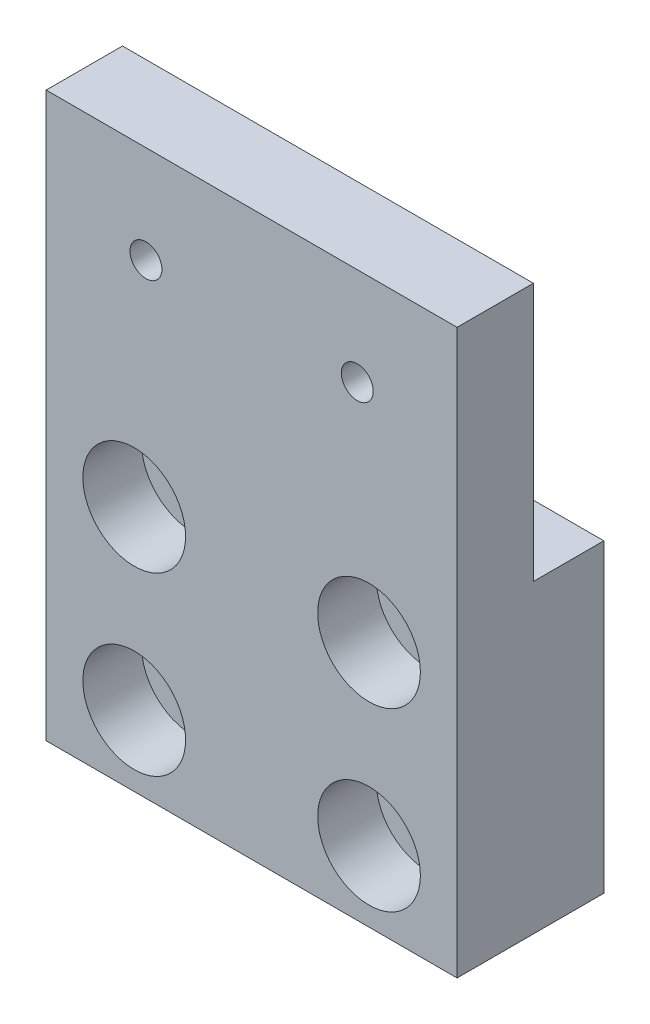
from build123d import *

# Parameters (mm, degrees)
SKETCH1_W                                        = 44.45
SKETCH1_H                                        = 60.96
BOSS_EXTRUDE1_DEPTH                              = 7.9375
CBORE_FOR_1_4_SOCKET_HEAD_CAP_SCREW1_D           = 6.7564
CBORE_FOR_1_4_SOCKET_HEAD_CAP_SCREW1_CBORE_D     = 11.1125
CBORE_FOR_1_4_SOCKET_HEAD_CAP_SCREW1_CBORE_DEPTH = 6.35
SKETCH4_W                                        = 7.62
SKETCH4_H                                        = 27.94
CUT_EXTRUDE1_DEPTH                               = 45.45
F_8_32_TAPPED_HOLE1_D                            = 3.4544


with BuildPart() as part:
    # Sketch1 → Boss-Extrude1 (new body, symmetric)
    with BuildSketch(Plane.XY):
        Rectangle(SKETCH1_W, SKETCH1_H)
    extrude(amount=BOSS_EXTRUDE1_DEPTH, both=True)

    # CBORE for 1/4 Socket Head Cap Screw1 (through all)
    with Locations(Plane.XY.offset(7.9375)):
        with Locations((-12.7, -3.81), (12.7, -3.81), (12.7, -22.86), (-12.7, -22.86)):
            CounterBoreHole(CBORE_FOR_1_4_SOCKET_HEAD_CAP_SCREW1_D / 2, CBORE_FOR_1_4_SOCKET_HEAD_CAP_SCREW1_CBORE_D / 2, CBORE_FOR_1_4_SOCKET_HEAD_CAP_SCREW1_CBORE_DEPTH)

    # Sketch4 → Cut-Extrude1 (cut, through all)
    with BuildSketch(Plane(origin=(22.225, 0, 0), x_dir=(0, 0, -1), z_dir=(1, 0, 0))):
        with Locations((4.1275, 16.51)):
            Rectangle(SKETCH4_W, SKETCH4_H)
    extrude(amount=-CUT_EXTRUDE1_DEPTH, mode=Mode.SUBTRACT)

    # #8-32 Tapped Hole1 (through all)
    with Locations(Plane.XY.offset(7.9375)):
        with Locations((-11.43, 19.939), (11.43, 19.939)):
            Hole(F_8_32_TAPPED_HOLE1_D / 2)


solid = part.part
